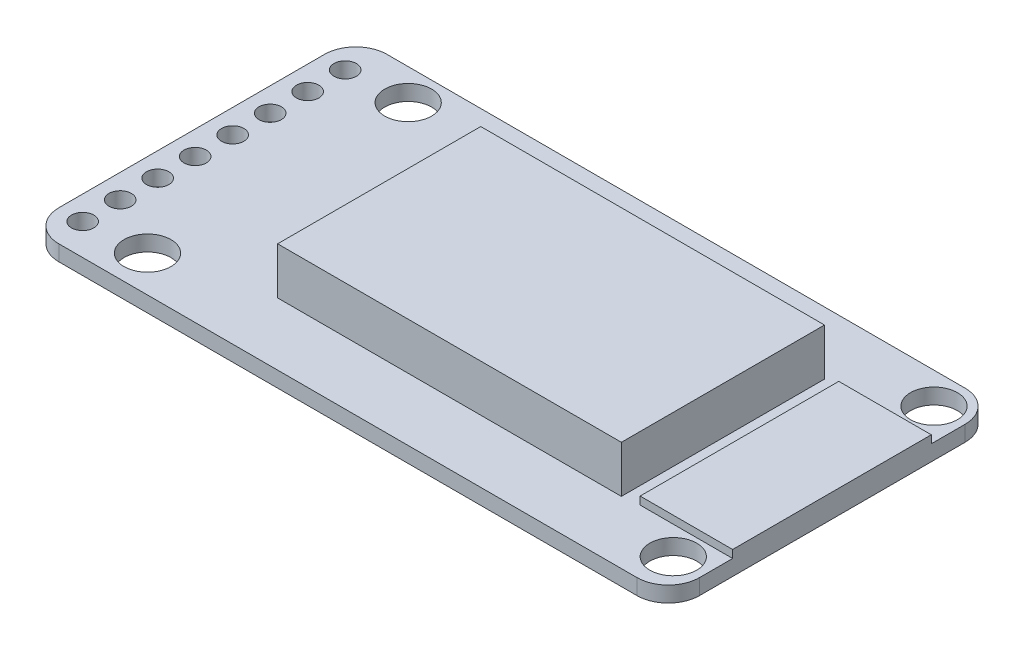
from build123d import *

# Parameters (mm, degrees)
CROQUIS1_W              = 41
CROQUIS1_H              = 21
SALIENTE_EXTRUIR1_DEPTH = 4
CROQUIS2_W              = 12
CROQUIS2_H              = 21.062925544
CORTAR_EXTRUIR1_DEPTH   = 3
CROQUIS3_W              = 7
CROQUIS3_H              = 21
CORTAR_EXTRUIR2_DEPTH   = 3
CROQUIS4_OUTSIDE_W      = 52.248
CROQUIS4_OUTSIDE_H      = 32.248
CROQUIS4_OUTSIDE_W_2    = 22
CROQUIS4_OUTSIDE_H_2    = 13
CORTAR_EXTRUIR3_DEPTH   = 3
REDONDEO1_R             = 2
CROQUIS5_R              = 0.71529937
CORTAR_EXTRUIR5_DEPTH   = 3
MATRIZL2_COUNT          = 8
MATRIZL2_PITCH          = 2.4
CROQUIS6_R              = 1.5
CORTAR_EXTRUIR6_DEPTH   = 3
CROQUIS7_W              = 5.91959288
CROQUIS7_H              = 12.713547862
SALIENTE_EXTRUIR2_DEPTH = 0.5


with BuildPart() as part:
    # Croquis1 → Saliente-Extruir1 (new body)
    with BuildSketch(Plane(origin=(0, 0, 0), x_dir=(1, 0, 0), z_dir=(0, 1, 0))):
        Rectangle(CROQUIS1_W, CROQUIS1_H)
    extrude(amount=SALIENTE_EXTRUIR1_DEPTH)

    # Croquis2 → Cortar-Extruir1 (cut)
    with BuildSketch(Plane(origin=(0, 4, 0), x_dir=(1, 0, 0), z_dir=(0, 1, 0))):
        with Locations((-14.5, -0.031462772)):
            Rectangle(CROQUIS2_W, CROQUIS2_H)
    extrude(amount=-CORTAR_EXTRUIR1_DEPTH, mode=Mode.SUBTRACT)

    # Croquis3 → Cortar-Extruir2 (cut)
    with BuildSketch(Plane(origin=(0, 4, 0), x_dir=(1, 0, 0), z_dir=(0, 1, 0))):
        with Locations((17, 0)):
            Rectangle(CROQUIS3_W, CROQUIS3_H)
    extrude(amount=-CORTAR_EXTRUIR2_DEPTH, mode=Mode.SUBTRACT)

    # Croquis4 outside → Cortar-Extruir3 (cut)
    with BuildSketch(Plane(origin=(0, 4, 0), x_dir=(1, 0, 0), z_dir=(0, 1, 0))):
        Rectangle(CROQUIS4_OUTSIDE_W, CROQUIS4_OUTSIDE_H)
        with Locations((2.5, 0)):
            Rectangle(CROQUIS4_OUTSIDE_W_2, CROQUIS4_OUTSIDE_H_2, mode=Mode.SUBTRACT)
    extrude(amount=-CORTAR_EXTRUIR3_DEPTH, mode=Mode.SUBTRACT)

    # Redondeo1
    redondeo1_edges = [part.edges().sort_by_distance(p)[0] for p in [
        (-20.5, 0.5, 10.5),
        (-20.5, 0.5, -10.5),
        (20.5, 0.5, 10.5),
        (20.5, 0.5, -10.5),
    ]]
    fillet(redondeo1_edges, radius=REDONDEO1_R)

    # Croquis5 → Cortar-Extruir5 (cut)
    with BuildSketch(Plane(origin=(0, 1, 0), x_dir=(1, 0, 0), z_dir=(0, 1, 0))):
        with Locations((-18.975797273, -8.5)):
            Circle(CROQUIS5_R)
    cortar_extruir5 = extrude(amount=-CORTAR_EXTRUIR5_DEPTH, mode=Mode.SUBTRACT)

    # MatrizL2: Cortar-Extruir5 ×8
    with Locations(*[(0, 0, -i * MATRIZL2_PITCH) for i in range(1, MATRIZL2_COUNT)]):
        add(cortar_extruir5, mode=Mode.SUBTRACT)

    # Croquis6 → Cortar-Extruir6 (cut)
    with BuildSketch(Plane(origin=(0, 1, 0), x_dir=(1, 0, 0), z_dir=(0, 1, 0))):
        with Locations((-15.149962862, 8.506455595)):
            Circle(CROQUIS6_R)
        with Locations((18.5, 8.506455595)):
            Circle(CROQUIS6_R)
        with Locations((-15.149962862, -8.178172234)):
            Circle(CROQUIS6_R)
        with Locations((18.5, -8.178172234)):
            Circle(CROQUIS6_R)
    extrude(amount=-CORTAR_EXTRUIR6_DEPTH, mode=Mode.SUBTRACT)

    # Croquis7 → Saliente-Extruir2 (add)
    with BuildSketch(Plane(origin=(0, 1, 0), x_dir=(1, 0, 0), z_dir=(0, 1, 0))):
        with Locations((17.54020356, -0.02363113)):
            Rectangle(CROQUIS7_W, CROQUIS7_H)
    extrude(amount=SALIENTE_EXTRUIR2_DEPTH)


solid = part.part
